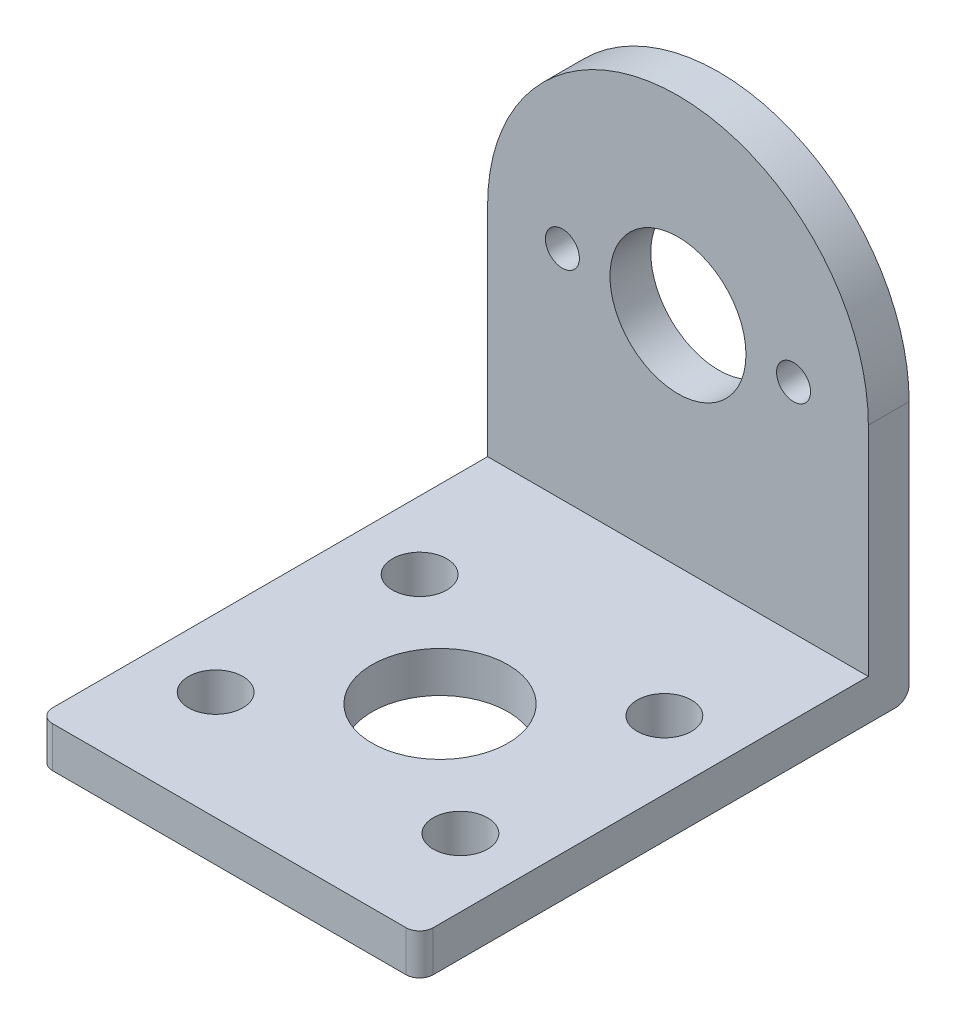
from build123d import *

# Parameters (mm, degrees)
SKETCH1_R           = 5
SKETCH1_R_2         = 1.25
BOSS_EXTRUDE1_DEPTH = 3
SKETCH2_W           = 28
SKETCH2_H           = 3
BOSS_EXTRUDE2_DEPTH = 33
FILLET1_R           = 1
SKETCH4_R           = 2
SKETCH4_R_2         = 5
CUT_EXTRUDE1_DEPTH  = 10


with BuildPart() as part:
    # Sketch1 → Boss-Extrude1 (new body)
    with BuildSketch(Plane.XY):
        with BuildLine():
            Line((-14, 0), (-14, -19))
            Line((-14, -19), (14, -19))
            Line((14, -19), (14, 0))
            ThreePointArc((14, 0), (0, 14), (-14, 0))
        make_face()
        Circle(SKETCH1_R, mode=Mode.SUBTRACT)
        with Locations((-8.5, 0)):
            Circle(SKETCH1_R_2, mode=Mode.SUBTRACT)
        with Locations((8.5, 0)):
            Circle(SKETCH1_R_2, mode=Mode.SUBTRACT)
    extrude(amount=BOSS_EXTRUDE1_DEPTH)

    # Sketch2 → Boss-Extrude2 (add)
    with BuildSketch(Plane.XY.offset(3)):
        with Locations((0, -17.5)):
            Rectangle(SKETCH2_W, SKETCH2_H)
    extrude(amount=BOSS_EXTRUDE2_DEPTH)

    # Fillet1
    fillet1_edges = [part.edges().sort_by_distance(p)[0] for p in [
        (-14, -17.5, 36),
        (14, -17.5, 36),
        (0, -19, 0),
    ]]
    fillet(fillet1_edges, radius=FILLET1_R)

    # Sketch4 → Cut-Extrude1 (cut)
    with BuildSketch(Plane.XZ.offset(19)):
        with Locations((-9, 28)):
            Circle(SKETCH4_R)
        with Locations((-9, 13)):
            Circle(SKETCH4_R)
        with Locations((9, 28)):
            Circle(SKETCH4_R)
        with Locations((9, 13)):
            Circle(SKETCH4_R)
        with Locations((0, 20.5)):
            Circle(SKETCH4_R_2)
    extrude(amount=-CUT_EXTRUDE1_DEPTH, mode=Mode.SUBTRACT)


solid = part.part
